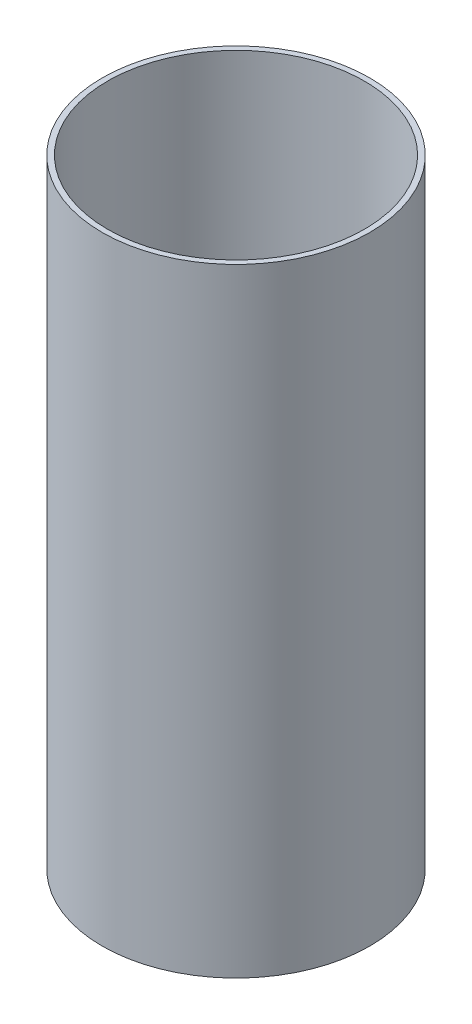
from build123d import *

# Parameters (mm, degrees)
SKETCH1_R           = 49.5046
SKETCH1_R_2         = 47.498
BOSS_EXTRUDE1_DEPTH = 228.6


with BuildPart() as part:
    # Sketch1 → Boss-Extrude1 (new body)
    with BuildSketch(Plane(origin=(0, 0, 0), x_dir=(1, 0, 0), z_dir=(0, 1, 0))):
        Circle(SKETCH1_R)
        Circle(SKETCH1_R_2, mode=Mode.SUBTRACT)
    extrude(amount=BOSS_EXTRUDE1_DEPTH)


solid = part.part
